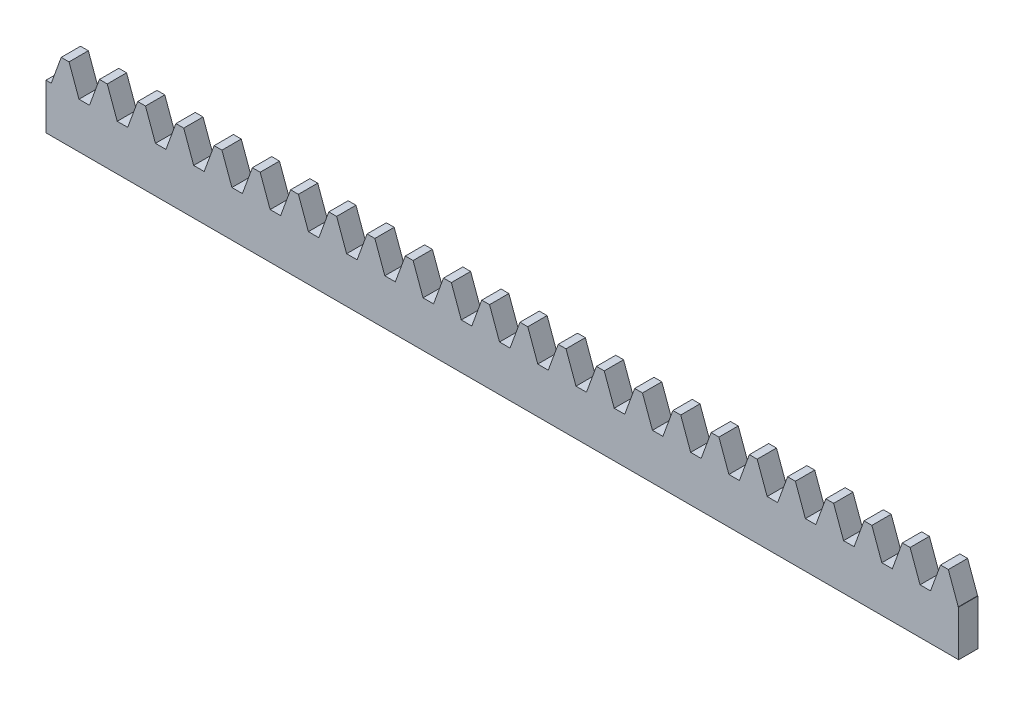
from build123d import *

# Parameters (mm, degrees)
BLANKSKE_W         = 150
BLANKSKE_H         = 12
BLANK_DEPTH        = 10
TOOTHCUTSIM_DEPTH  = 151.811140172
TEETHCUTS_COUNT    = 25
TEETHCUTS_PITCH    = 6.2831853
CUT_EXTRUDE1_DEPTH = 6.825


with BuildPart() as part:
    # BlankSke → Blank (new body)
    with BuildSketch(Plane.XY):
        with Locations((75, 6)):
            Rectangle(BLANKSKE_W, BLANKSKE_H)
    extrude(amount=-BLANK_DEPTH)

    # TooCutSkeSim → ToothCutSim (cut, through all)
    with BuildSketch(Plane.XY):
        Polygon((0.861870739, 7.5), (-0.861870739, 7.5), (-2.508981637, 12.0254), (2.508981637, 12.0254), align=None)
    toothcutsim = extrude(amount=-TOOTHCUTSIM_DEPTH, mode=Mode.SUBTRACT)

    # TeethCuts: ToothCutSim ×25
    with Locations(*[(i * TEETHCUTS_PITCH, 0, 0) for i in range(1, TEETHCUTS_COUNT)]):
        add(toothcutsim, mode=Mode.SUBTRACT)

    # Sketch1 → Cut-Extrude1 (cut)
    with BuildSketch(Plane.XY):
        Polygon((150, 7.5), (149.934576461, 7.5), (148.296710406, 12), (147.012998694, 12), (145.375132639, 7.5), (143.651391161, 7.5), (142.013525106, 12), (140.729813394, 12), (139.091947339, 7.5), (137.368205861, 7.5), (135.730339806, 12), (134.446628094, 12), (132.808762039, 7.5), (131.085020561, 7.5), (129.447154506, 12), (128.163442794, 12), (126.525576739, 7.5), (124.801835261, 7.5), (123.163969206, 12), (121.880257494, 12), (120.242391439, 7.5), (118.518649961, 7.5), (116.880783906, 12), (115.597072194, 12), (113.959206139, 7.5), (112.235464661, 7.5), (110.597598606, 12), (109.313886894, 12), (107.676020839, 7.5), (105.952279361, 7.5), (104.314413306, 12), (103.030701594, 12), (101.392835539, 7.5), (99.669094061, 7.5), (98.031228006, 12), (96.747516294, 12), (95.109650239, 7.5), (93.385908761, 7.5), (91.748042706, 12), (90.464330994, 12), (88.826464939, 7.5), (87.102723461, 7.5), (85.464857406, 12), (84.181145694, 12), (82.543279639, 7.5), (80.819538161, 7.5), (79.181672106, 12), (77.897960394, 12), (76.260094339, 7.5), (74.536352861, 7.5), (72.898486806, 12), (71.614775094, 12), (69.976909039, 7.5), (68.253167561, 7.5), (66.615301506, 12), (65.331589794, 12), (63.693723739, 7.5), (61.969982261, 7.5), (60.332116206, 12), (59.048404494, 12), (57.410538439, 7.5), (55.686796961, 7.5), (54.048930906, 12), (52.765219194, 12), (51.127353139, 7.5), (49.403611661, 7.5), (47.765745606, 12), (46.482033894, 12), (44.844167839, 7.5), (43.120426361, 7.5), (41.482560306, 12), (40.198848594, 12), (38.560982539, 7.5), (36.837241061, 7.5), (35.199375006, 12), (33.915663294, 12), (32.277797239, 7.5), (30.554055761, 7.5), (28.916189706, 12), (27.632477994, 12), (25.994611939, 7.5), (24.270870461, 7.5), (22.633004406, 12), (21.349292694, 12), (19.711426639, 7.5), (17.987685161, 7.5), (16.349819106, 12), (15.066107394, 12), (13.428241339, 7.5), (11.704499861, 7.5), (10.066633806, 12), (8.782922094, 12), (7.145056039, 7.5), (5.421314561, 7.5), (3.783448506, 12), (2.499736794, 12), (0.861870739, 7.5), (0, 7.5), (0, 0), (150, 0), align=None)
    extrude(amount=-CUT_EXTRUDE1_DEPTH, mode=Mode.SUBTRACT)


solid = part.part
